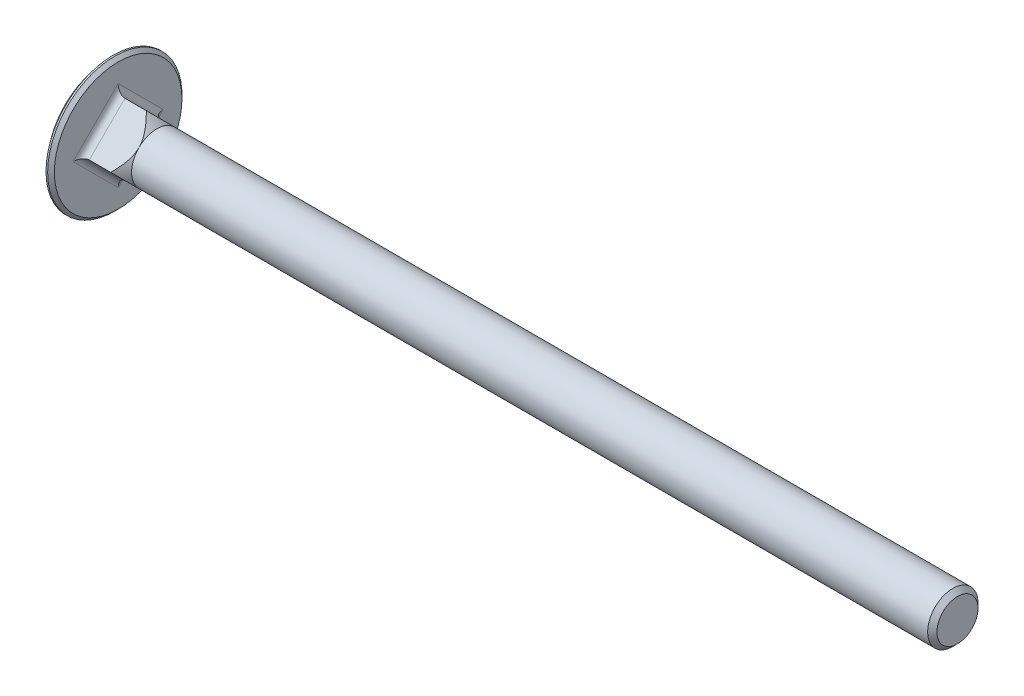
from build123d import *

# Parameters (mm, degrees)
BOSS_EXTRUDE1_DEPTH = 4.6
FILLET1_R           = 0.8


with BuildPart() as part:
    # BodySke → Base-Revolve (revolve)
    with BuildSketch(Plane.XY):
        with BuildLine():
            Line((3.0024, 8), (3.6, 8))
            Line((3.6, 8), (3.6, 3))
            Line((3.6, 3), (103.0455, 3))
            Line((103.0455, 3), (103.6, 2.4455))
            Line((103.6, 2.4455), (103.6, 0))
            Line((103.6, 0), (0, 0))
            ThreePointArc((0, 0), (0.775318389, 4.272423369), (3.0024, 8))
        make_face()
    revolve(axis=Axis((-31.75, 0, 0), (1, 0, 0)))

    # Sketch1 → Boss-Extrude1 (add)
    with BuildSketch(Plane(origin=(3.6, 0, 0), x_dir=(0, 0, -1), z_dir=(1, 0, 0))):
        Polygon((0, 4.242640687), (4.242640687, 0), (0, -4.242640687), (-4.242640687, 0), align=None)
    extrude(amount=BOSS_EXTRUDE1_DEPTH)

    # Sketch2 → Cut-Revolve1 (revolve, cut)
    with BuildSketch(Plane.XY):
        Polygon((8.2, 3), (13.2, 3), (13.2, 9), (2.2, 9), align=None)
    revolve(axis=Axis((0, 0, 0), (1, 0, 0)), mode=Mode.SUBTRACT)

    # Fillet1
    fillet1_edges = [part.edges().sort_by_distance(p)[0] for p in [
        (3.6, 2.121320344, -2.121320344),
        (3.6, -2.121320344, -2.121320344),
        (3.6, 2.121320344, 2.121320344),
        (3.6, -2.121320344, 2.121320344),
    ]]
    fillet(fillet1_edges, radius=FILLET1_R)


solid = part.part
